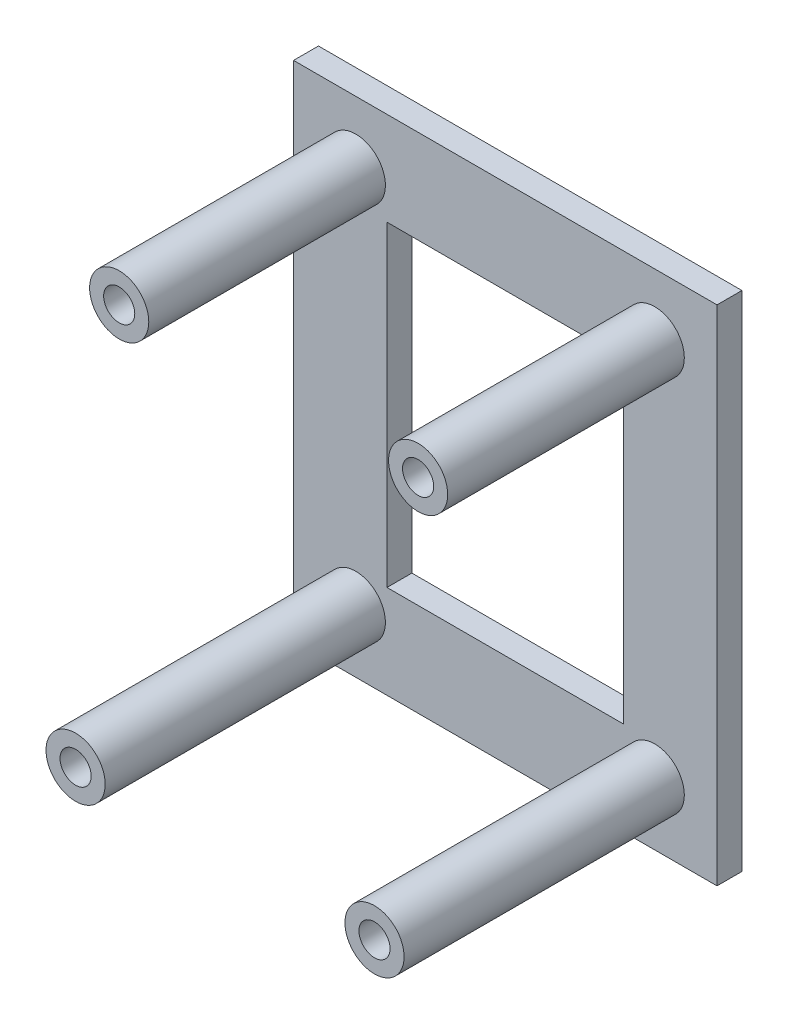
from build123d import *

# Parameters (mm, degrees)
SKETCH1_W           = 34
SKETCH1_H           = 40.4
SKETCH1_W_2         = 19
SKETCH1_H_2         = 25.4
BOSS_EXTRUDE1_DEPTH = 2
SKETCH1_3_R         = 2.375
BOSS_EXTRUDE2_DEPTH = 21
CUT_EXTRUDE1_START  = 21
SKETCH1_4_R         = 1.25
CUT_EXTRUDE1_DEPTH  = 15
SKETCH1_6_R         = 2.375
BOSS_EXTRUDE3_DEPTH = 24.5
CUT_EXTRUDE2_START  = 24.5
SKETCH1_8_R         = 1.25
CUT_EXTRUDE2_DEPTH  = 18.5


with BuildPart() as part:
    # Sketch1 → Boss-Extrude1 (new body)
    with BuildSketch(Plane.XY):
        with Locations((12, 0)):
            Rectangle(SKETCH1_W, SKETCH1_H)
        with Locations((12, 0)):
            Rectangle(SKETCH1_W_2, SKETCH1_H_2, mode=Mode.SUBTRACT)
    extrude(amount=BOSS_EXTRUDE1_DEPTH)

    # Sketch1_3 → Boss-Extrude2 (add)
    with BuildSketch(Plane.XY):
        with Locations((0, 15.2)):
            Circle(SKETCH1_3_R)
        with Locations((24, 15.2)):
            Circle(SKETCH1_3_R)
    extrude(amount=BOSS_EXTRUDE2_DEPTH)

    # Sketch1_4 → Cut-Extrude1 (cut)
    with BuildSketch(Plane.XY.offset(CUT_EXTRUDE1_START)):
        with Locations((0, 15.2)):
            Circle(SKETCH1_4_R)
        with Locations((24, 15.2)):
            Circle(SKETCH1_4_R)
        with Locations((24, -15.2)):
            Circle(SKETCH1_4_R)
        with Locations((0, -15.2)):
            Circle(SKETCH1_4_R)
    extrude(amount=-CUT_EXTRUDE1_DEPTH, mode=Mode.SUBTRACT)

    # Sketch1_6 → Boss-Extrude3 (add)
    with BuildSketch(Plane.XY):
        with Locations((24, -15.2)):
            Circle(SKETCH1_6_R)
        with Locations((0, -15.2)):
            Circle(SKETCH1_6_R)
    extrude(amount=BOSS_EXTRUDE3_DEPTH)

    # Sketch1_8 → Cut-Extrude2 (cut)
    with BuildSketch(Plane.XY.offset(CUT_EXTRUDE2_START)):
        with Locations((0, -15.2)):
            Circle(SKETCH1_8_R)
        with Locations((24, -15.2)):
            Circle(SKETCH1_8_R)
    extrude(amount=-CUT_EXTRUDE2_DEPTH, mode=Mode.SUBTRACT)


solid = part.part
